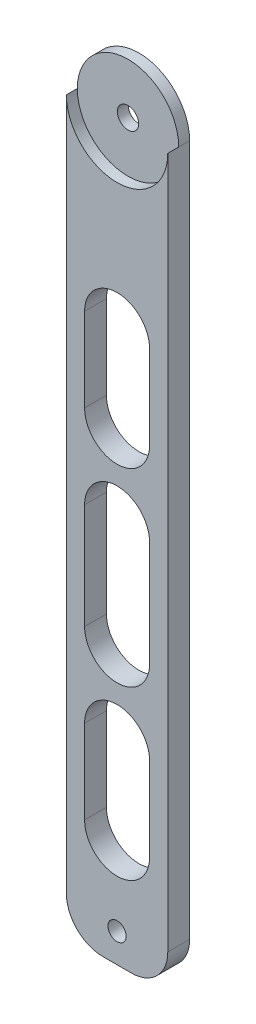
from build123d import *

# Parameters (mm, degrees)
ESQUISSE1_W             = 27.85
ESQUISSE1_H             = 200
BOSS_EXTRU_2_DEPTH      = 6
ESQUISSE3_R             = 2.5
ENL_V_MAT_EXTRU_1_DEPTH = 6
ESQUISSE4_R             = 13.925
ENL_V_MAT_EXTRU_2_DEPTH = 3
ESQUISSE5_R             = 2.925
ENL_V_MAT_EXTRU_3_DEPTH = 3
ESQUISSE6_W             = 17.85
ESQUISSE6_H             = 23
ESQUISSE6_H_2           = 29
ENL_V_MAT_EXTRU_4_DEPTH = 10
CONG_1_R                = 10
CONG_2_R                = 10


with BuildPart() as part:
    # Esquisse1 → Boss.-Extru.2 (new body)
    with BuildSketch(Plane.XY):
        with Locations((1.835077519, -78.788662791)):
            Rectangle(ESQUISSE1_W, ESQUISSE1_H)
        with BuildLine():
            Line((-12.089922481, 21.211337209), (15.760077519, 21.211337209))
            ThreePointArc((15.760077519, 21.211337209), (1.835077519, 35.136337209), (-12.089922481, 21.211337209))
        make_face()
    extrude(amount=BOSS_EXTRU_2_DEPTH)

    # Esquisse3 → Enlèv. mat.-Extru.1 (cut)
    with BuildSketch(Plane.XY.offset(6)):
        with Locations((1.835077519, -170.788662791)):
            Circle(ESQUISSE3_R)
    extrude(amount=-ENL_V_MAT_EXTRU_1_DEPTH, mode=Mode.SUBTRACT)

    # Esquisse4 → Enlèv. mat.-Extru.2 (cut)
    with BuildSketch(Plane.XY.offset(6)):
        with Locations((1.835077519, 21.211337209)):
            Circle(ESQUISSE4_R)
    extrude(amount=-ENL_V_MAT_EXTRU_2_DEPTH, mode=Mode.SUBTRACT)

    # Esquisse5 → Enlèv. mat.-Extru.3 (cut)
    with BuildSketch(Plane.XY.offset(3)):
        with Locations((1.835077519, 21.211337209)):
            Circle(ESQUISSE5_R)
    extrude(amount=-ENL_V_MAT_EXTRU_3_DEPTH, mode=Mode.SUBTRACT)

    # Esquisse6 → Enlèv. mat.-Extru.4 (cut)
    with BuildSketch(Plane.XY.offset(6)):
        with BuildLine():
            Line((-7.089922481, -27.788662791), (10.760077519, -27.788662791))
            ThreePointArc((10.760077519, -27.788662791), (1.835077519, -18.863662791), (-7.089922481, -27.788662791))
        make_face()
        with Locations((1.835077519, -39.288662791)):
            Rectangle(ESQUISSE6_W, ESQUISSE6_H)
        with BuildLine():
            Line((-7.089922481, -50.788662791), (10.760077519, -50.788662791))
            ThreePointArc((10.760077519, -50.788662791), (1.835077519, -59.713662791), (-7.089922481, -50.788662791))
        make_face()
        with BuildLine():
            ThreePointArc((-7.089922481, -73.788662791), (1.835077519, -64.863662791), (10.760077519, -73.788662791))
            Line((10.760077519, -73.788662791), (-7.089922481, -73.788662791))
        make_face()
        with Locations((1.835077519, -88.288662791)):
            Rectangle(ESQUISSE6_W, ESQUISSE6_H_2)
        with BuildLine():
            Line((-7.089922481, -102.788662791), (10.760077519, -102.788662791))
            ThreePointArc((10.760077519, -102.788662791), (1.835077519, -111.713662791), (-7.089922481, -102.788662791))
        make_face()
        with BuildLine():
            Line((-7.089922481, -125.788662791), (10.760077519, -125.788662791))
            ThreePointArc((10.760077519, -125.788662791), (1.835077519, -116.863662791), (-7.089922481, -125.788662791))
        make_face()
        with Locations((1.835077519, -137.288662791)):
            Rectangle(ESQUISSE6_W, ESQUISSE6_H)
        with BuildLine():
            Line((-7.089922481, -148.788662791), (10.760077519, -148.788662791))
            ThreePointArc((10.760077519, -148.788662791), (1.835077519, -157.713662791), (-7.089922481, -148.788662791))
        make_face()
    extrude(amount=-ENL_V_MAT_EXTRU_4_DEPTH, mode=Mode.SUBTRACT)

    # Congé1
    cong_1_edges = [part.edges().sort_by_distance(p)[0] for p in [
        (-12.089922481, -178.788662791, 3),
    ]]
    fillet(cong_1_edges, radius=CONG_1_R)

    # Congé2
    cong_2_edges = [part.edges().sort_by_distance(p)[0] for p in [
        (15.760077519, -178.788662791, 3),
    ]]
    fillet(cong_2_edges, radius=CONG_2_R)


solid = part.part
